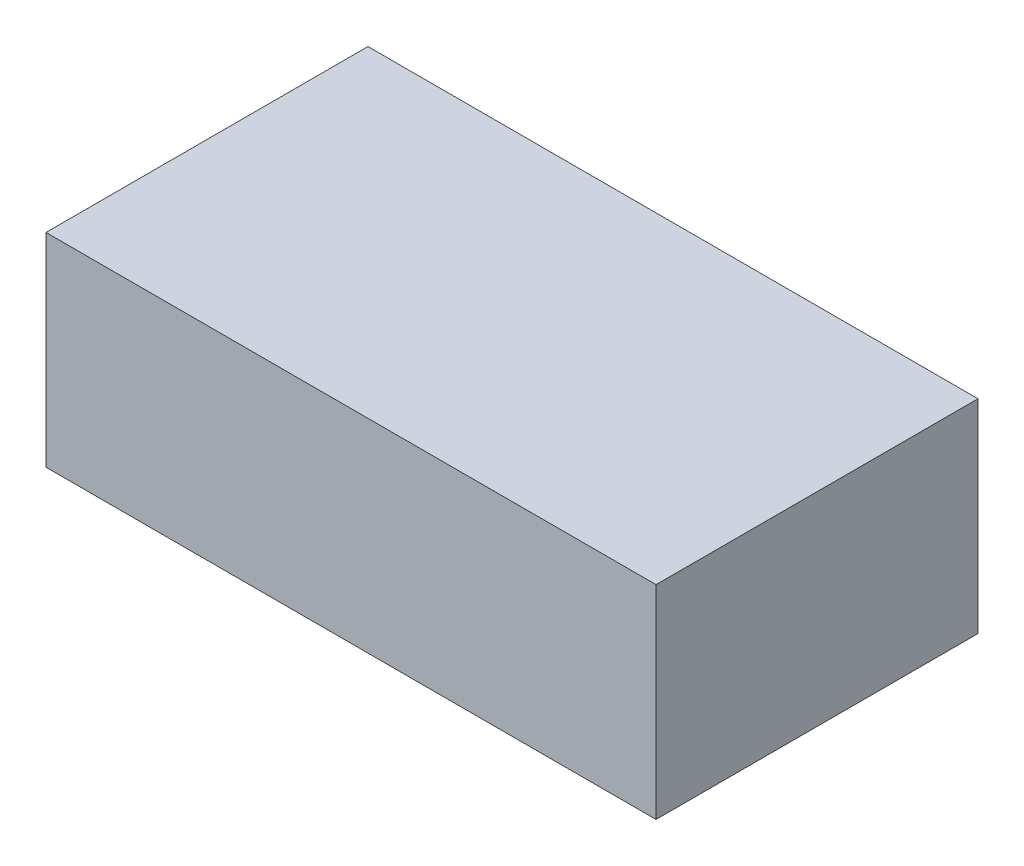
from build123d import *

# Parameters (mm, degrees)
SKETCH1_W           = 91.44
SKETCH1_H           = 48.26
BOSS_EXTRUDE1_DEPTH = 30.48


with BuildPart() as part:
    # Sketch1 → Boss-Extrude1 (new body)
    with BuildSketch(Plane(origin=(0, 0, 0), x_dir=(1, 0, 0), z_dir=(0, 1, 0))):
        with Locations((45.72, 24.13)):
            Rectangle(SKETCH1_W, SKETCH1_H)
    extrude(amount=BOSS_EXTRUDE1_DEPTH)


solid = part.part
